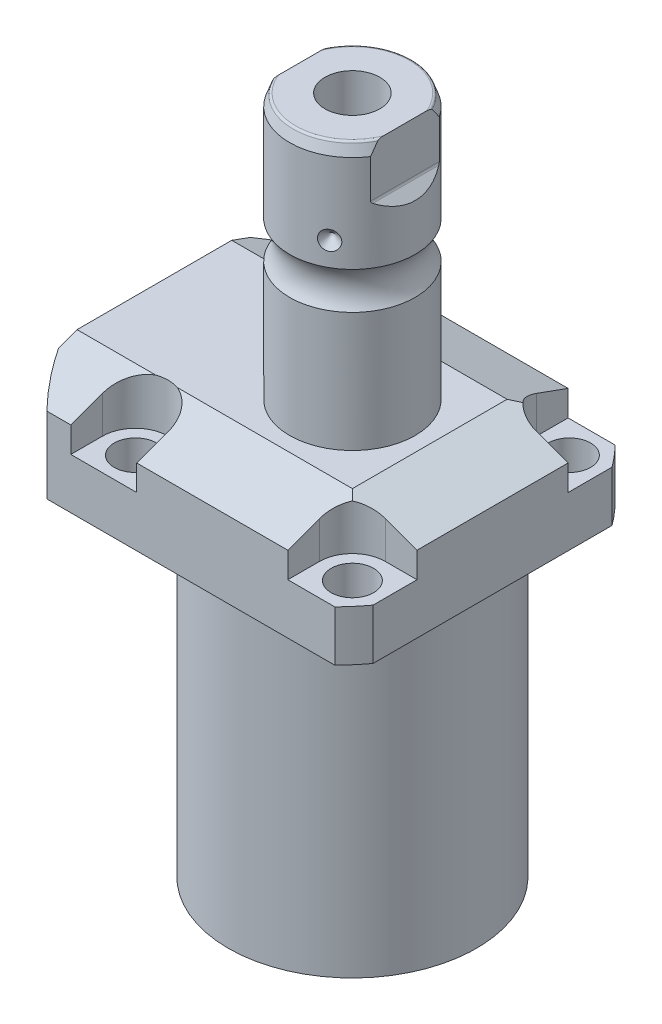
from build123d import *

# Parameters (mm, degrees)
SKETCH1_W                = 70.866
SKETCH1_H                = 85.496
EXTRUDE1_DEPTH           = 104.521
SKETCH2_OUTSIDE_W        = 117.996
SKETCH2_OUTSIDE_H        = 103.366
SKETCH2_OUTSIDE_R        = 50.8
CUT_EXTRUDE1_DEPTH       = 105.521
SKETCH3_W                = 45.1992
SKETCH3_H                = 79.502
FILLET1_R                = 0.381
CUT_EXTRUDE2_DEPTH       = 12.243
CUT_EXTRUDE9_START       = -51.063
CUT_EXTRUDE9_DEPTH       = 87.496
CUT_EXTRUDE7_DEPTH       = 36.433
CUT_EXTRUDE7_DEPTH_BACK  = 36.433
SKETCH10_R               = 1.1811
SKETCH17_W               = 5.3594
SKETCH17_H               = 12.776
HOLE1_AT_2_COUNT         = 2
HOLE1_AT_2_PITCH         = 54.864
HOLE1_AT_3_COUNT         = 2
HOLE1_AT_3_PITCH         = 77.589412886
HOLE1_AT_4_COUNT         = 2
HOLE1_AT_4_PITCH         = 54.864
CHAMFER1_SIZE            = 0.635
FILLET2_R                = 0.635
CIRPATTERN1_COUNT        = 3
CUT_EXTRUDE10_DEPTH      = 36.433
CUT_EXTRUDE10_DEPTH_BACK = 36.433


with BuildPart() as part:
    # Sketch1 → Extrude1 (new body)
    with BuildSketch(Plane(origin=(0, 0, 0), x_dir=(0, 0, 1), z_dir=(0, -1, 0))):
        with Locations((0, 7.315)):
            Rectangle(SKETCH1_W, SKETCH1_H)
    extrude(amount=-EXTRUDE1_DEPTH)

    # Sketch2 outside → Cut-Extrude1 (cut, through all)
    with BuildSketch(Plane.XZ):
        with Locations((-7.315, 0)):
            Rectangle(SKETCH2_OUTSIDE_W, SKETCH2_OUTSIDE_H)
        with Locations((-5.4102, 0)):
            Circle(SKETCH2_OUTSIDE_R, mode=Mode.SUBTRACT)
    extrude(amount=-CUT_EXTRUDE1_DEPTH, mode=Mode.SUBTRACT)

    # Sketch3 → Cut-Revolve1 (revolve, cut)
    with BuildSketch(Plane(origin=(0, 0, 0), x_dir=(0, 0, -1), z_dir=(1, 0, 0))):
        with Locations((53.9941, 39.751)):
            Rectangle(SKETCH3_W, SKETCH3_H)
    revolve(axis=Axis((0, -93.345, 0), (0, 1, 0)), mode=Mode.SUBTRACT)

    # Fillet1
    fillet1_edges = [part.edges().sort_by_distance(p)[0] for p in [
        (0, 79.502, 31.3945),
    ]]
    fillet(fillet1_edges, radius=FILLET1_R)

    # Sketch4 → Cut-Extrude2 (cut)
    with BuildSketch(Plane(origin=(0, 104.521, 0), x_dir=(-1, 0, 0), z_dir=(0, 1, 0))):
        with BuildLine():
            Line((-19.1008, -35.433), (-19.1008, -27.432))
            ThreePointArc((-19.1008, -27.432), (-21.540951985, -21.540951985), (-27.432, -19.1008))
            Line((-27.432, -19.1008), (-35.433, -19.1008))
            Line((-35.433, -19.1008), (-35.433, -35.433))
            Line((-35.433, -35.433), (-19.1008, -35.433))
        make_face()
        with BuildLine():
            Line((35.7632, -35.433), (19.1008, -35.433))
            Line((19.1008, -35.433), (19.1008, -27.432))
            ThreePointArc((19.1008, -27.432), (27.432, -19.1008), (35.7632, -27.432))
            Line((35.7632, -27.432), (35.7632, -35.433))
        make_face()
        with BuildLine():
            Line((19.1008, 35.433), (19.1008, 27.432))
            ThreePointArc((19.1008, 27.432), (27.432, 19.1008), (35.7632, 27.432))
            Line((35.7632, 27.432), (35.7632, 35.433))
            Line((35.7632, 35.433), (19.1008, 35.433))
        make_face()
        with BuildLine():
            Line((-27.432, 19.1008), (-35.433, 19.1008))
            Line((-35.433, 19.1008), (-35.433, 35.433))
            Line((-35.433, 35.433), (-19.1008, 35.433))
            Line((-19.1008, 35.433), (-19.1008, 27.432))
            ThreePointArc((-19.1008, 27.432), (-21.540951985, 21.540951985), (-27.432, 19.1008))
        make_face()
    extrude(amount=-CUT_EXTRUDE2_DEPTH, mode=Mode.SUBTRACT)

    # Sketch5 → Cut-Extrude9 (cut)
    with BuildSketch(Plane(origin=(0, 0, 0), x_dir=(0, 0, -1), z_dir=(1, 0, 0)).offset(CUT_EXTRUDE9_START)):
        Polygon((-19.558, 104.521), (-35.433, 98.742972531), (-35.433, 104.521), align=None)
    cut_extrude9 = extrude(amount=CUT_EXTRUDE9_DEPTH, mode=Mode.SUBTRACT)

    # Mirror1: Cut-Extrude9 across plane
    add(cut_extrude9.mirror(Plane.XY), mode=Mode.SUBTRACT)

    # Sketch9 → Cut-Extrude7 (cut, two sides)
    with BuildSketch(Plane.XY) as cut_extrude7_sk:
        Polygon((19.558, 104.521), (35.433, 98.742972531), (35.433, 104.521), align=None)
    extrude(amount=CUT_EXTRUDE7_DEPTH, mode=Mode.SUBTRACT)
    extrude(cut_extrude7_sk.sketch, amount=-CUT_EXTRUDE7_DEPTH_BACK, mode=Mode.SUBTRACT)

    # Sketch20 → Cut-Revolve4 (revolve, cut)
    with BuildSketch(Plane(origin=(-35.0774, 88.9, -18.1102), x_dir=(0, 1, 0), z_dir=(1, 0, 0)), mode=Mode.PRIVATE) as cut_revolve4_sk:
        Polygon((-9.398, 38.3413), (-7.9502, 38.3413), (-7.9502, 35.8902), (-6.9342, 35.8902), (-6.9342, 33.8836), (4.0386, 33.8836), (4.0386, 32.639), (-9.398, 32.639), align=None)
    cut_revolve4 = revolve(cut_revolve4_sk.sketch.rotate(Axis((-35.0774, 81.620304954, 14.5288), (0, 1, 0)), 180), axis=Axis((-35.0774, 81.620304954, 14.5288), (0, 1, 0)), mode=Mode.SUBTRACT)  # turned: the seam where the file's is

    # Mirror10: Cut-Revolve4 across plane
    add(cut_revolve4.mirror(Plane.XY), mode=Mode.SUBTRACT)

    # Sketch15 → Revolve3 (revolve)
    with BuildSketch(Plane(origin=(0, 0, 0), x_dir=(0, 0, -1), z_dir=(1, 0, 0)), mode=Mode.PRIVATE) as revolve3_sk:
        with BuildLine():
            Line((0, 104.521), (15.875, 104.521))
            Line((15.875, 104.521), (15.875, 134.76390643))
            ThreePointArc((15.875, 134.76390643), (14.3256, 139.471), (15.875, 144.17809357))
            Line((15.875, 144.17809357), (15.875, 168.65599416))
            Line((15.875, 168.65599416), (14.81184082, 171.577))
            Line((14.81184082, 171.577), (0, 171.577))
            Line((0, 171.577), (0, 104.521))
        make_face()
    revolve(revolve3_sk.sketch.rotate(Axis((0, 250.290824608, 0), (0, -1, 0)), 180), axis=Axis((0, 250.290824608, 0), (0, -1, 0)))  # turned: the seam where the file's is

    # Sketch17 → Hole1 (revolve, cut)
    with BuildSketch(Plane(origin=(27.432, 92.278, -27.432), x_dir=(0, 0, 1), z_dir=(1, 0, 0))):
        with Locations((2.6797, 6.388)):
            Rectangle(SKETCH17_W, SKETCH17_H)
    hole1 = revolve(axis=Axis((27.432, -17.722, -27.432), (0, 1, 0)), mode=Mode.SUBTRACT)

    # Hole1 at 2: Hole1 ×2
    with Locations(*[(0, 0, i * HOLE1_AT_2_PITCH) for i in range(1, HOLE1_AT_2_COUNT)]):
        add(hole1, mode=Mode.SUBTRACT)

    # Hole1 at 3: Hole1 ×2
    with Locations(*[Vector(-0.707106781, 0, 0.707106781) * (i * HOLE1_AT_3_PITCH) for i in range(1, HOLE1_AT_3_COUNT)]):
        add(hole1, mode=Mode.SUBTRACT)

    # Hole1 at 4: Hole1 ×2
    with Locations(*[(-i * HOLE1_AT_4_PITCH, 0, 0) for i in range(1, HOLE1_AT_4_COUNT)]):
        add(hole1, mode=Mode.SUBTRACT)

    # Chamfer1
    chamfer1_edges = [part.edges().sort_by_distance(p)[0] for p in [
        (-35.0774, 81.9658, 15.7734),
        (-35.0774, 81.9658, -15.7734),
    ]]
    chamfer(chamfer1_edges, length=CHAMFER1_SIZE)

    # Sketch21 → Cut-Revolve5 (revolve, cut)
    with BuildSketch(Plane.XZ.offset(-92.5068)):
        Polygon((-50.063, -1.9304), (-49.809, -1.9304), (-49.809, -6.3246), (-49.0978, -7.0358), (-35.6358, -7.0358), (-35.6358, -12.9794), (-50.063, -12.9794), align=None)
    cut_revolve5 = revolve(axis=Axis((-57.549532301, 92.5068, -12.9794), (1, 0, 0)), mode=Mode.SUBTRACT)

    # Mirror13: Cut-Revolve5 across plane
    add(cut_revolve5.mirror(Plane.XY), mode=Mode.SUBTRACT)

    # Fillet2
    fillet2_edges = [part.edges().sort_by_distance(p)[0] for p in [
        (0, 171.577, -14.81184082),
    ]]
    fillet(fillet2_edges, radius=FILLET2_R)

    # Sketch26 → Cut-Revolve7 (revolve, cut)
    with BuildSketch(Plane.XY, mode=Mode.PRIVATE) as cut_revolve7_sk:
        Polygon((-15.875, 152.572), (-13.462, 150.159), (-15.875, 150.159), align=None)
    cut_revolve7 = revolve(cut_revolve7_sk.sketch.rotate(Axis((-39.772000707, 150.159, 0), (1, 0, 0)), 90), axis=Axis((-39.772000707, 150.159, 0), (1, 0, 0)), mode=Mode.SUBTRACT)  # turned: the seam where the file's is

    # CirPattern1: Cut-Revolve7 ×3 about axis
    cirpattern1_axis = Axis((0, 250.290824608, 0), (0, 1, 0))
    for i in range(1, CIRPATTERN1_COUNT):
        add(cut_revolve7.rotate(cirpattern1_axis, i * 360 / CIRPATTERN1_COUNT), mode=Mode.SUBTRACT)

    # Sketch27 → Hole2 (revolve, cut)
    with BuildSketch(Plane(origin=(0, 171.577, 0), x_dir=(0, 0, 1), z_dir=(1, 0, 0))):
        Polygon((0, 0), (0, 29.566487704), (6.9342, 25.4), (6.9342, 0), align=None)
    revolve(axis=Axis((0, 175.821199587, 0), (0, -1, 0)), mode=Mode.SUBTRACT)

    # Sketch29 → Cut-Extrude10 (cut, two sides)
    with BuildSketch(Plane.XY) as cut_extrude10_sk:
        with BuildLine():
            Line((13.284, 171.577), (13.284, 158.877))
            ThreePointArc((13.284, 158.877), (13.342003912, 158.585394643), (13.507185078, 158.338183558))
            Line((13.507185078, 158.338183558), (15.875, 155.970368636))
            Line((15.875, 155.970368636), (15.875, 171.577))
            Line((15.875, 171.577), (13.284, 171.577))
        make_face()
        with BuildLine():
            Line((-15.875, 171.577), (-13.284, 171.577))
            Line((-13.284, 171.577), (-13.284, 158.877))
            ThreePointArc((-13.284, 158.877), (-13.342003912, 158.585394643), (-13.507185078, 158.338183558))
            Line((-13.507185078, 158.338183558), (-15.875, 155.970368636))
            Line((-15.875, 155.970368636), (-15.875, 171.577))
        make_face()
    extrude(amount=CUT_EXTRUDE10_DEPTH, mode=Mode.SUBTRACT)
    extrude(cut_extrude10_sk.sketch, amount=-CUT_EXTRUDE10_DEPTH_BACK, mode=Mode.SUBTRACT)


with BuildPart() as body_2:
    # Sketch10 → Revolve4 (revolve)
    with BuildSketch(Plane(origin=(-35.0774, 88.9, -18.1102), x_dir=(0, 1, 0), z_dir=(1, 0, 0))):
        with Locations((-9.1313, 8.1026)):
            Circle(SKETCH10_R)
    revolve(axis=Axis((-35.0774, 87.86749, -14.5288), (0, 1, 0)))


with BuildPart() as body_3:
    # Mirror12: mirrored copy
    add(body_2.part.mirror(Plane.XY))


solid = Compound([part.part, body_2.part, body_3.part])
